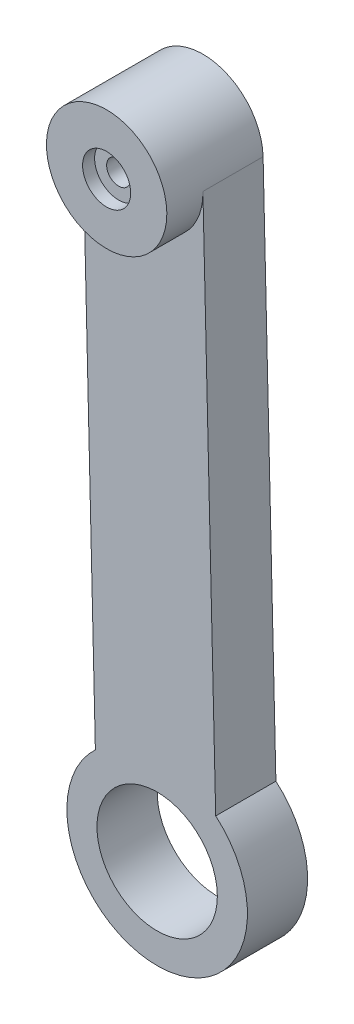
from build123d import *

# Parameters (mm, degrees)
SKETCH1_R           = 2.4
SKETCH1_R_2         = 5
BOSS_EXTRUDE1_DEPTH = 5
SKETCH2_R           = 5
SKETCH2_R_2         = 1
BOSS_EXTRUDE2_DEPTH = 3
SKETCH3_R           = 2
CUT_EXTRUDE1_DEPTH  = 1


with BuildPart() as part:
    # Sketch1 → Boss-Extrude1 (new body)
    with BuildSketch(Plane(origin=(0, 0, 0), x_dir=(0.999713496, 0.023935854, 0), z_dir=(0, 0, 1))):
        with BuildLine():
            Line((10.010039278, 5.570210903), (10.010039278, 49.980040959))
            ThreePointArc((10.010039278, 49.980040959), (5.010039278, 54.980040959), (0.010039278, 49.980040959))
            Line((0.010039278, 49.980040959), (0.010039278, 5.570210903))
            ThreePointArc((0.010039278, 5.570210903), (5.010039278, -7.519959041), (10.010039278, 5.570210903))
        make_face()
        with Locations((5.010039278, 49.980040959)):
            Circle(SKETCH1_R, mode=Mode.SUBTRACT)
        with Locations((5.010039278, -0.019959041)):
            Circle(SKETCH1_R_2, mode=Mode.SUBTRACT)
    extrude(amount=BOSS_EXTRUDE1_DEPTH)

    # Sketch2 → Boss-Extrude2 (add)
    with BuildSketch(Plane.XY.offset(5)):
        with Locations((3.812288906, 50.085641068)):
            Circle(SKETCH2_R)
        with Locations((3.812288906, 50.085641068)):
            Circle(SKETCH2_R_2, mode=Mode.SUBTRACT)
    extrude(amount=BOSS_EXTRUDE2_DEPTH)

    # Sketch3 → Cut-Extrude1 (cut)
    with BuildSketch(Plane.XY.offset(8)):
        with Locations((3.812288906, 50.085641068)):
            Circle(SKETCH3_R)
    extrude(amount=-CUT_EXTRUDE1_DEPTH, mode=Mode.SUBTRACT)


solid = part.part
